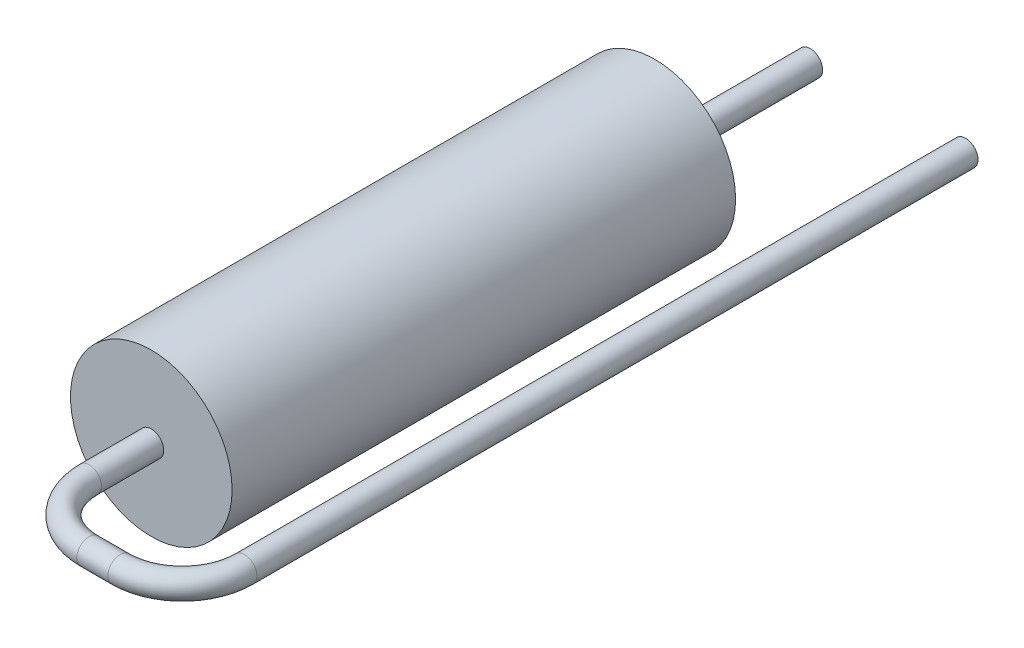
from build123d import *

# Parameters (mm, degrees)
SKETCH2_R           = 2.6
RESISTOR_BODY_DEPTH = 16.2
LEAD1_PROFILE_R     = 0.4
SKETCH6_R           = 0.4
LEAD2_DEPTH         = 5


with BuildPart() as part:
    # Sketch2 → Resistor Body (new body)
    with BuildSketch(Plane.XY):
        Circle(SKETCH2_R)
    extrude(amount=RESISTOR_BODY_DEPTH)

    # Lead1: sweep along a path in Lead1 Path
    with BuildLine(Plane(origin=(0, 0, 0), x_dir=(1, 0, 0), z_dir=(0, 1, 0))) as lead1_path:
        Line((0, -16.2), (0, -18.2))
        ThreePointArc((0, -18.2), (0.585786438, -19.614213562), (2, -20.2))
        Line((2, -20.2), (3, -20.2))
        ThreePointArc((3, -20.2), (4.414213562, -19.614213562), (5, -18.2))
        Line((5, -18.2), (5, 5))
    # Lead1 Profile → Lead1 (sweep)
    with BuildSketch(Plane(origin=(0, 0, 16.2), x_dir=(-1, 0, 0), z_dir=(0, 0, 1))):
        Circle(LEAD1_PROFILE_R)
    sweep(path=lead1_path.line)

    # Sketch6 → Lead2 (add)
    with BuildSketch(Plane(origin=(0, 0, 0), x_dir=(1, 0, 0), z_dir=(0, 0, -1))):
        Circle(SKETCH6_R)
    extrude(amount=LEAD2_DEPTH)


solid = part.part
